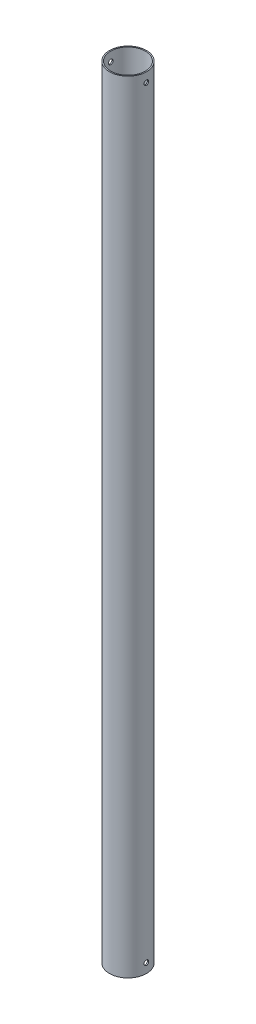
from build123d import *

# Parameters (mm, degrees)
SKETCH2_R           = 24.97201
SKETCH2_R_2         = 23.38451
EXTRUDE_THIN1_DEPTH = 1054.1
SKETCH4_R           = 3.175
CUT_EXTRUDE1_DEPTH  = 25.97201


with BuildPart() as part:
    # Sketch2 → Extrude-Thin1 (new body)
    with BuildSketch(Plane(origin=(0, 0, 0), x_dir=(1, 0, 0), z_dir=(0, 1, 0))):
        Circle(SKETCH2_R)
        Circle(SKETCH2_R_2, mode=Mode.SUBTRACT)
    extrude(amount=EXTRUDE_THIN1_DEPTH)

    # Sketch4 → Cut-Extrude1 (cut, symmetric)
    with BuildSketch(Plane(origin=(0, 0, 0), x_dir=(0, 0, -1), z_dir=(1, 0, 0))):
        with Locations((0, 1041.4)):
            Circle(SKETCH4_R)
    cut_extrude1 = extrude(amount=CUT_EXTRUDE1_DEPTH, both=True, mode=Mode.SUBTRACT)

    # Mirror1: Cut-Extrude1 across plane
    add(cut_extrude1.mirror(Plane.ZX.offset(527.05)), mode=Mode.SUBTRACT)


solid = part.part
